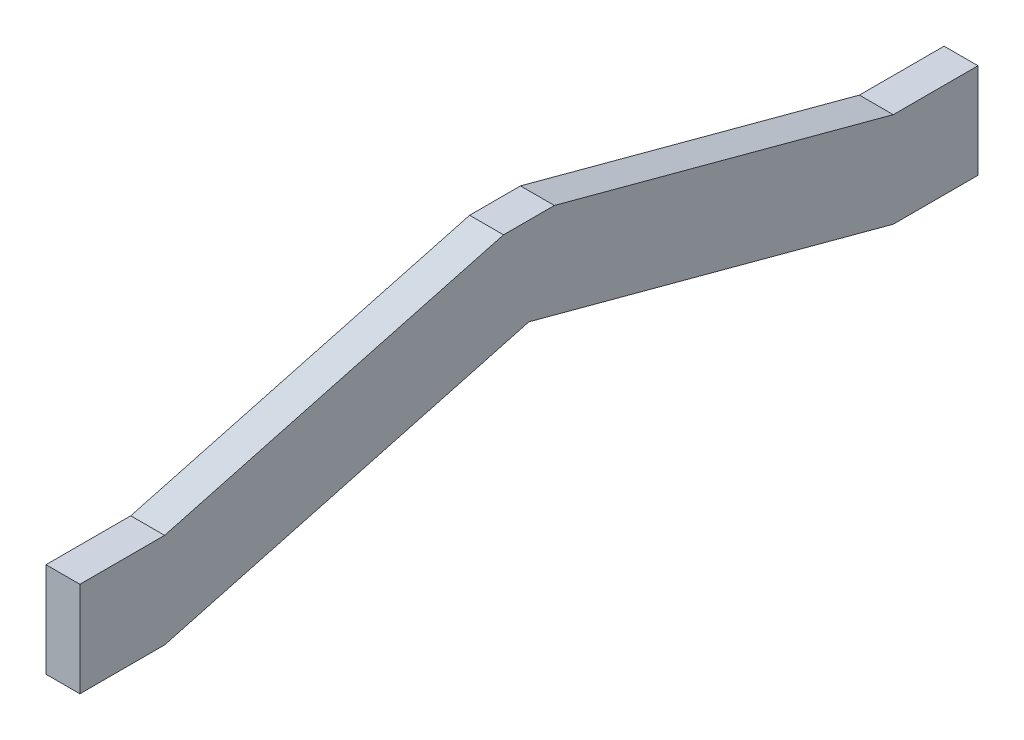
from build123d import *

# Parameters (mm, degrees)
BOSS_EXTRUDE1_DEPTH = 10


with BuildPart() as part:
    # Sketch1 → Boss-Extrude1 (new body)
    with BuildSketch(Plane(origin=(0, 0, 0), x_dir=(0, 0, -1), z_dir=(1, 0, 0))):
        Polygon((0, 0), (-25, 0), (-132.5, 28.804538186), (-240, 0), (-265, 0), (-265, 28), (-240, 28), (-140, 54.794919243), (-125, 54.794919243), (-25, 28), (0, 28), align=None)
    extrude(amount=BOSS_EXTRUDE1_DEPTH)


solid = part.part
